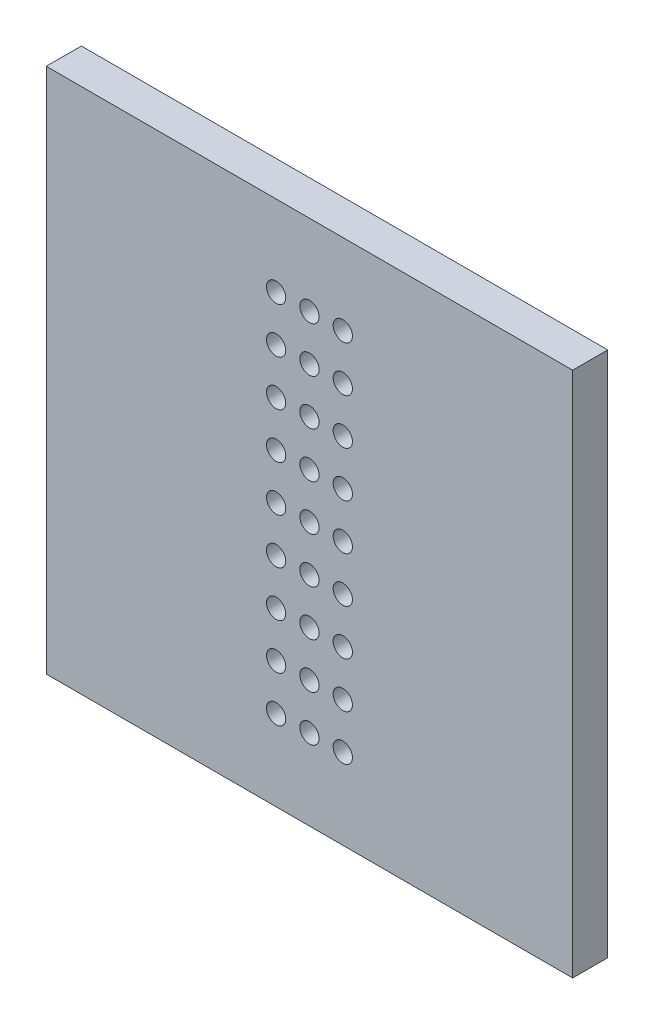
from build123d import *

# Parameters (mm, degrees)
ESQUISSE1_W            = 30
ESQUISSE1_H            = 30
BASE_PLATE_DEPTH       = 2
SKETCH_PERFORATIONS_R  = 0.55
CUT_PERFORATIONS_DEPTH = 10


with BuildPart() as part:
    # Esquisse1 → Base_Plate (new body)
    with BuildSketch(Plane.XY):
        Rectangle(ESQUISSE1_W, ESQUISSE1_H)
    extrude(amount=BASE_PLATE_DEPTH)

    # Sketch_Perforations → Cut_Perforations (cut)
    with BuildSketch(Plane.XY.offset(2)):
        with Locations((-1.9, -10.4)):
            Circle(SKETCH_PERFORATIONS_R)
        with Locations((-1.9, -7.8)):
            Circle(SKETCH_PERFORATIONS_R)
        with Locations((-1.9, -5.2)):
            Circle(SKETCH_PERFORATIONS_R)
        with Locations((-1.9, -2.6)):
            Circle(SKETCH_PERFORATIONS_R)
        with Locations((-1.9, 0)):
            Circle(SKETCH_PERFORATIONS_R)
        with Locations((-1.9, 2.6)):
            Circle(SKETCH_PERFORATIONS_R)
        with Locations((-1.9, 5.2)):
            Circle(SKETCH_PERFORATIONS_R)
        with Locations((-1.9, 7.8)):
            Circle(SKETCH_PERFORATIONS_R)
        with Locations((-1.9, 10.4)):
            Circle(SKETCH_PERFORATIONS_R)
        with Locations((0, -10.4)):
            Circle(SKETCH_PERFORATIONS_R)
        with Locations((0, -7.8)):
            Circle(SKETCH_PERFORATIONS_R)
        with Locations((0, -5.2)):
            Circle(SKETCH_PERFORATIONS_R)
        with Locations((0, -2.6)):
            Circle(SKETCH_PERFORATIONS_R)
        Circle(SKETCH_PERFORATIONS_R)
        with Locations((0, 2.6)):
            Circle(SKETCH_PERFORATIONS_R)
        with Locations((0, 5.2)):
            Circle(SKETCH_PERFORATIONS_R)
        with Locations((0, 7.8)):
            Circle(SKETCH_PERFORATIONS_R)
        with Locations((0, 10.4)):
            Circle(SKETCH_PERFORATIONS_R)
        with Locations((1.9, -10.4)):
            Circle(SKETCH_PERFORATIONS_R)
        with Locations((1.9, -7.8)):
            Circle(SKETCH_PERFORATIONS_R)
        with Locations((1.9, -5.2)):
            Circle(SKETCH_PERFORATIONS_R)
        with Locations((1.9, -2.6)):
            Circle(SKETCH_PERFORATIONS_R)
        with Locations((1.9, 0)):
            Circle(SKETCH_PERFORATIONS_R)
        with Locations((1.9, 2.6)):
            Circle(SKETCH_PERFORATIONS_R)
        with Locations((1.9, 5.2)):
            Circle(SKETCH_PERFORATIONS_R)
        with Locations((1.9, 7.8)):
            Circle(SKETCH_PERFORATIONS_R)
        with Locations((1.9, 10.4)):
            Circle(SKETCH_PERFORATIONS_R)
    extrude(amount=-CUT_PERFORATIONS_DEPTH, mode=Mode.SUBTRACT)


solid = part.part
